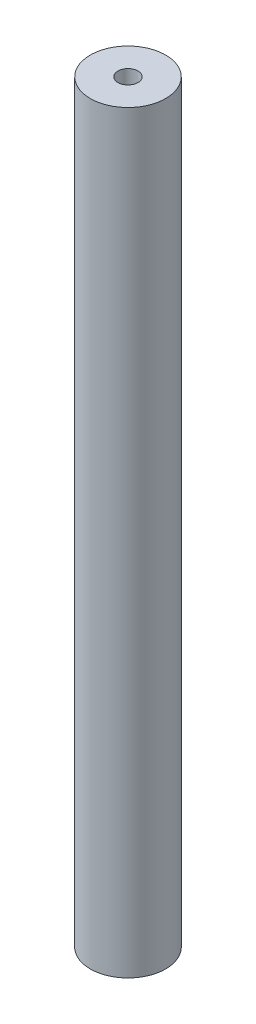
from build123d import *

# Parameters (mm, degrees)
CROQUIS1_R              = 15
CROQUIS1_R_2            = 4
SALIENTE_EXTRUIR1_DEPTH = 300


with BuildPart() as part:
    # Croquis1 → Saliente-Extruir1 (new body)
    with BuildSketch(Plane(origin=(0, 0, 0), x_dir=(1, 0, 0), z_dir=(0, 1, 0))):
        Circle(CROQUIS1_R)
        Circle(CROQUIS1_R_2, mode=Mode.SUBTRACT)
    extrude(amount=SALIENTE_EXTRUIR1_DEPTH)


solid = part.part
